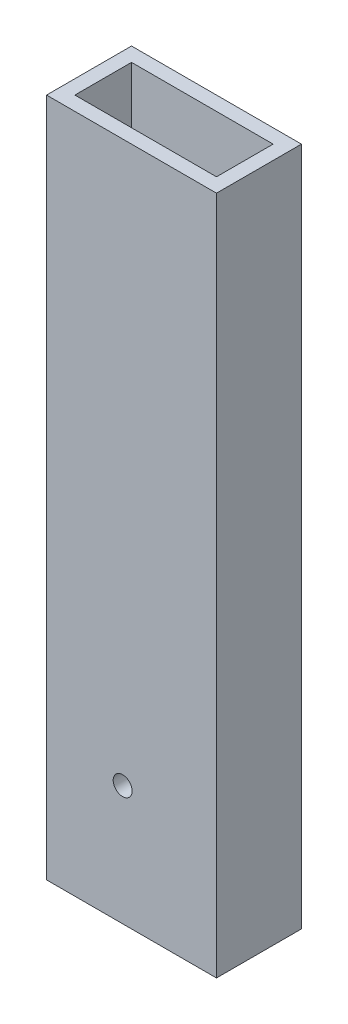
from build123d import *

# Parameters (mm, degrees)
SKETCH1_W           = 38.1
SKETCH1_H           = 19.05
SKETCH1_W_2         = 31.75
SKETCH1_H_2         = 12.7
BOSS_EXTRUDE1_DEPTH = 152.4
SKETCH2_R           = 2.125
CUT_EXTRUDE1_DEPTH  = 20.05


with BuildPart() as part:
    # Sketch1 → Boss-Extrude1 (new body)
    with BuildSketch(Plane(origin=(0, 0, 0), x_dir=(1, 0, 0), z_dir=(0, 1, 0))):
        with Locations((19.05, 9.525)):
            Rectangle(SKETCH1_W, SKETCH1_H)
        with Locations((19.05, 9.525)):
            Rectangle(SKETCH1_W_2, SKETCH1_H_2, mode=Mode.SUBTRACT)
    extrude(amount=BOSS_EXTRUDE1_DEPTH)

    # Sketch2 → Cut-Extrude1 (cut, through all)
    with BuildSketch(Plane(origin=(0, 0, -19.05), x_dir=(-1, 0, 0), z_dir=(0, 0, -1))):
        with Locations((-17.062243871, 26.832679639)):
            Circle(SKETCH2_R)
    extrude(amount=-CUT_EXTRUDE1_DEPTH, mode=Mode.SUBTRACT)


solid = part.part
